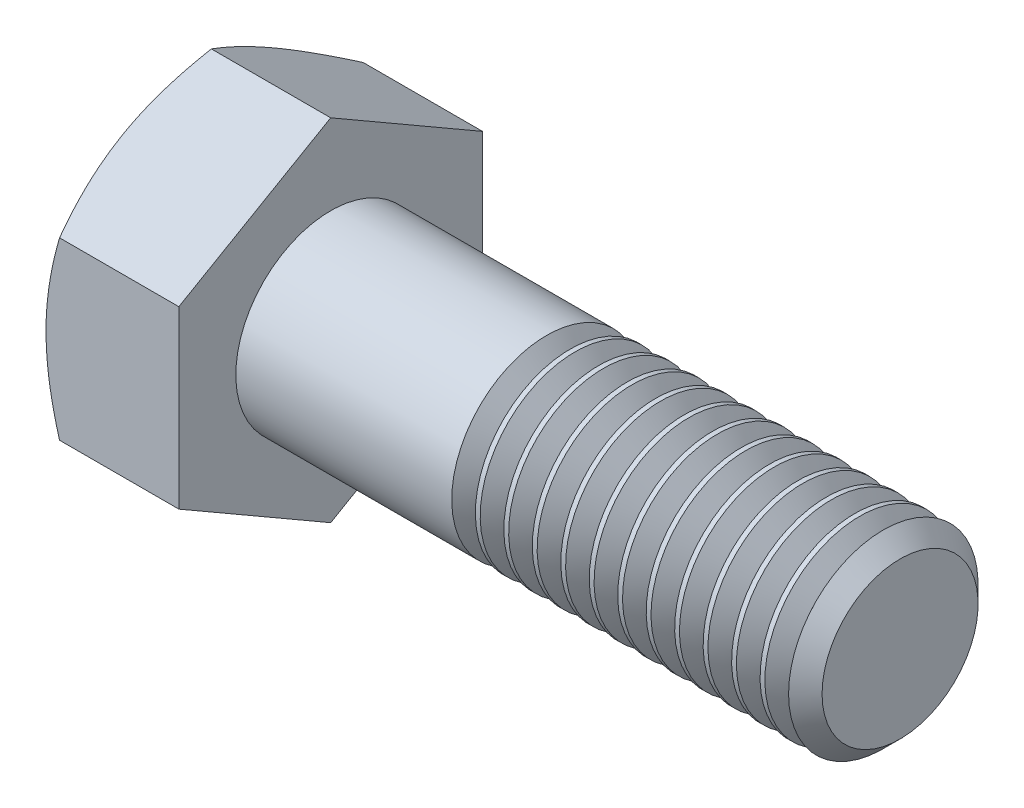
from build123d import *

# Parameters (mm, degrees)
BASEHEAD_DEPTH  = 3.5
THDSCHPAT_COUNT = 12
THDSCHPAT_PITCH = 0.75


with BuildPart() as part:
    # Sketch1 → BaseHead (new body)
    with BuildSketch(Plane(origin=(0, 0, 0), x_dir=(0, 0, -1), z_dir=(1, 0, 0))):
        Polygon((4, 2.309401077), (4, -2.309401077), (0, -4.618802154), (-4, -2.309401077), (-4, 2.309401077), (0, 4.618802154), align=None)
    extrude(amount=BASEHEAD_DEPTH)

    # BodySke → BaseBody (revolve)
    with BuildSketch(Plane.XY):
        Polygon((0, 0), (18.5, 0), (18.5, 2.055), (18.055, 2.5), (0, 2.5), align=None)
    revolve(axis=Axis((0, 0, 0), (1, 0, 0)))

    # Sketch3 → HeadChamfer (revolve, cut)
    with BuildSketch(Plane.XY):
        Polygon((0, 4), (3.244016936, 9.618802154), (3.244016936, 14.618802154), (-10, 14.618802154), (-10, 4), align=None)
    revolve(axis=Axis((0, 0, 0), (1, 0, 0)), mode=Mode.SUBTRACT)

    # ThdSchSke → ThreadSchematic (revolve, cut)
    with BuildSketch(Plane.XY):
        Polygon((9.5, -2.055), (9.188407645, -2.5), (9.188407645, -3.125), (9.811592355, -3.125), (9.811592355, -2.5), align=None)
    threadschematic = revolve(axis=Axis((-3.175, 0, 0), (1, 0, 0)), mode=Mode.SUBTRACT)

    # ThdSchPat: ThreadSchematic ×12
    with Locations(*[(i * THDSCHPAT_PITCH, 0, 0) for i in range(1, THDSCHPAT_COUNT)]):
        add(threadschematic, mode=Mode.SUBTRACT)


solid = part.part
